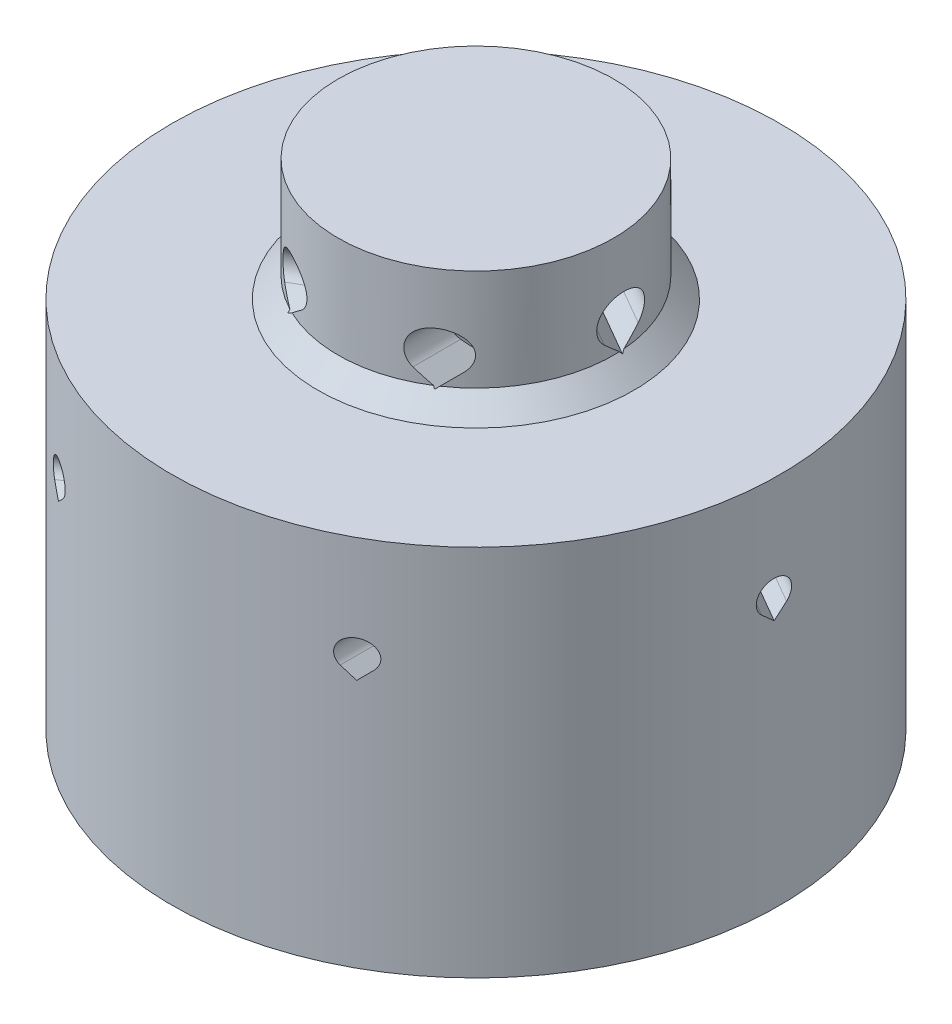
from build123d import *

# Parameters (mm, degrees)
SKETCH3_W          = 4.445
SKETCH3_H          = 1.5875
CUT_EXTRUDE1_DEPTH = 29.136842118
CIRPATTERN1_COUNT  = 6
CUT_EXTRUDE2_DEPTH = 29.136842118
CIRPATTERN2_COUNT  = 6


with BuildPart() as part:
    # Sketch1 → Revolve1 (revolve)
    with BuildSketch(Plane.XY):
        Polygon((-5.3975, 0), (-5.3975, -3.96875), (-6.19125, -4.7625), (-11.90625, -4.7625), (-11.90625, -7.1755), (-6.35, -7.1755), (-6.35, -7.9375), (-4.60375, -7.9375), (-4.60375, -13.346282015), (-3.33375, -14.616282015), (-3.33375, -16.8275), (-2.54, -16.8275), (-2.54, -14.2875), (-3.81, -13.0175), (-3.81, -1.5875), (-4.445, -1.5875), (-4.445, 0), align=None)
    revolve(axis=Axis((0, -1.5875, 0), (0, -1, 0)))

    # Sketch2 → Revolve2 (revolve)
    with BuildSketch(Plane.XY):
        Polygon((-6.35, -7.9375), (-6.35, -14.2875), (-4.445, -16.1925), (-4.445, -22.5425), (-6.35, -22.5425), (-6.35, -19.3675), (-7.3152, -19.3675), (-7.3152, -17.3863), (-10.3886, -17.3863), (-10.3886, -19.3675), (-11.90625, -19.3675), (-11.90625, -7.1755), (-6.35, -7.1755), align=None)
    revolve(axis=Axis((0, -1.5875, 0), (0, -1, 0)))

    # Sketch3 → Revolve3 (revolve)
    with BuildSketch(Plane.XY):
        with Locations((-2.2225, -0.79375)):
            Rectangle(SKETCH3_W, SKETCH3_H)
    revolve(axis=Axis((0, -1.5875, 0), (0, 1, 0)))

    # Sketch8 → Cut-Extrude1 (cut, through all)
    with BuildSketch(Plane.XY):
        with BuildLine():
            Line((-2.9718, -4.042893808), (-3.564496904, -3.450196904))
            ThreePointArc((-3.564496904, -3.450196904), (-2.9718, -2.0193), (-2.379103096, -3.450196904))
            Line((-2.379103096, -3.450196904), (-2.9718, -4.042893808))
        make_face()
    cut_extrude1 = extrude(amount=-CUT_EXTRUDE1_DEPTH, mode=Mode.SUBTRACT)

    # CirPattern1: Cut-Extrude1 ×6 about axis
    cirpattern1_axis = Axis((0, 42.935, 0), (0, -1, 0))
    for i in range(1, CIRPATTERN1_COUNT):
        add(cut_extrude1.rotate(cirpattern1_axis, i * 360 / CIRPATTERN1_COUNT), mode=Mode.SUBTRACT)

    # Sketch9 → Cut-Extrude2 (cut, through all)
    with BuildSketch(Plane.XY):
        with BuildLine():
            Line((-5.7546875, -9.604899011), (-6.175637006, -9.183949506))
            ThreePointArc((-6.175637006, -9.183949506), (-5.7546875, -8.1676875), (-5.333737994, -9.183949506))
            Line((-5.333737994, -9.183949506), (-5.7546875, -9.604899011))
        make_face()
    cut_extrude2 = extrude(amount=-CUT_EXTRUDE2_DEPTH, mode=Mode.SUBTRACT)

    # CirPattern2: Cut-Extrude2 ×6 about axis
    cirpattern2_axis = Axis((0, 42.935, 0), (0, -1, 0))
    for i in range(1, CIRPATTERN2_COUNT):
        add(cut_extrude2.rotate(cirpattern2_axis, i * 360 / CIRPATTERN2_COUNT), mode=Mode.SUBTRACT)


solid = part.part
